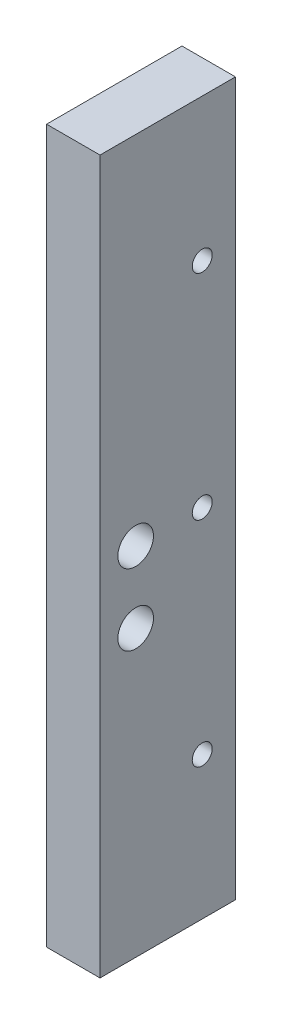
from build123d import *

# Parameters (mm, degrees)
SKETCH1_W           = 9.525
SKETCH1_H           = 127
BOSS_EXTRUDE1_DEPTH = 24.13
SKETCH2_R           = 1.778
CUT_EXTRUDE1_DEPTH  = 10.525
SKETCH3_R           = 3.175
CUT_EXTRUDE2_DEPTH  = 38.1


with BuildPart() as part:
    # Sketch1 → Boss-Extrude1 (new body)
    with BuildSketch(Plane.XY):
        with Locations((4.7625, 63.5)):
            Rectangle(SKETCH1_W, SKETCH1_H)
    extrude(amount=BOSS_EXTRUDE1_DEPTH)

    # Sketch2 → Cut-Extrude1 (cut, through all)
    with BuildSketch(Plane.ZY):
        with Locations((5.9182, 101.6)):
            Circle(SKETCH2_R)
        with Locations((5.9182, 63.5)):
            Circle(SKETCH2_R)
        with Locations((5.9182, 25.4)):
            Circle(SKETCH2_R)
    extrude(amount=-CUT_EXTRUDE1_DEPTH, mode=Mode.SUBTRACT)

    # Sketch3 → Cut-Extrude2 (cut)
    with BuildSketch(Plane(origin=(9.525, 0, 0), x_dir=(0, 0, -1), z_dir=(1, 0, 0))):
        with Locations((-17.78, 63.5)):
            Circle(SKETCH3_R)
        with Locations((-17.78, 50.8)):
            Circle(SKETCH3_R)
    extrude(amount=-CUT_EXTRUDE2_DEPTH, mode=Mode.SUBTRACT)


solid = part.part
